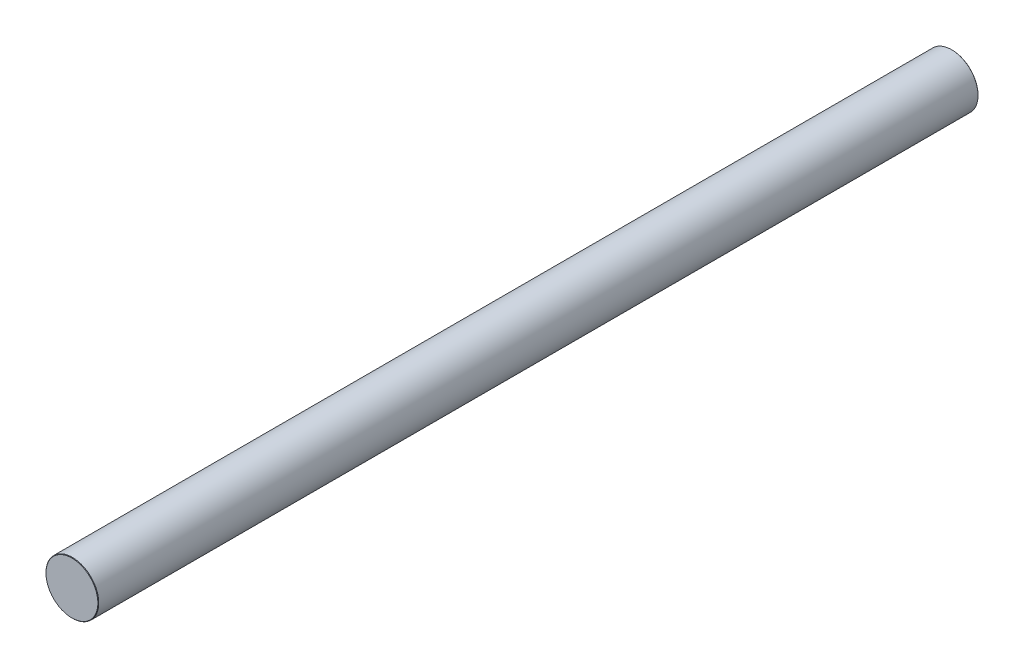
from build123d import *

# Parameters (mm, degrees)
SKETCH_1_R      = 6
EXTRUDE_1_DEPTH = 200
CHAMFER_1_SIZE  = 0.1


with BuildPart() as part:
    # Эскиз1 → Бобышка-Вытянуть1 (new body)
    with BuildSketch(Plane.XY):
        Circle(SKETCH_1_R)
    extrude(amount=EXTRUDE_1_DEPTH)

    # Фаска1
    chamfer_1_edges = [part.edges().sort_by_distance(p)[0] for p in [
        (-6, 0, 0),
        (-6, 0, 200),
    ]]
    chamfer(chamfer_1_edges, length=CHAMFER_1_SIZE)


solid = part.part
